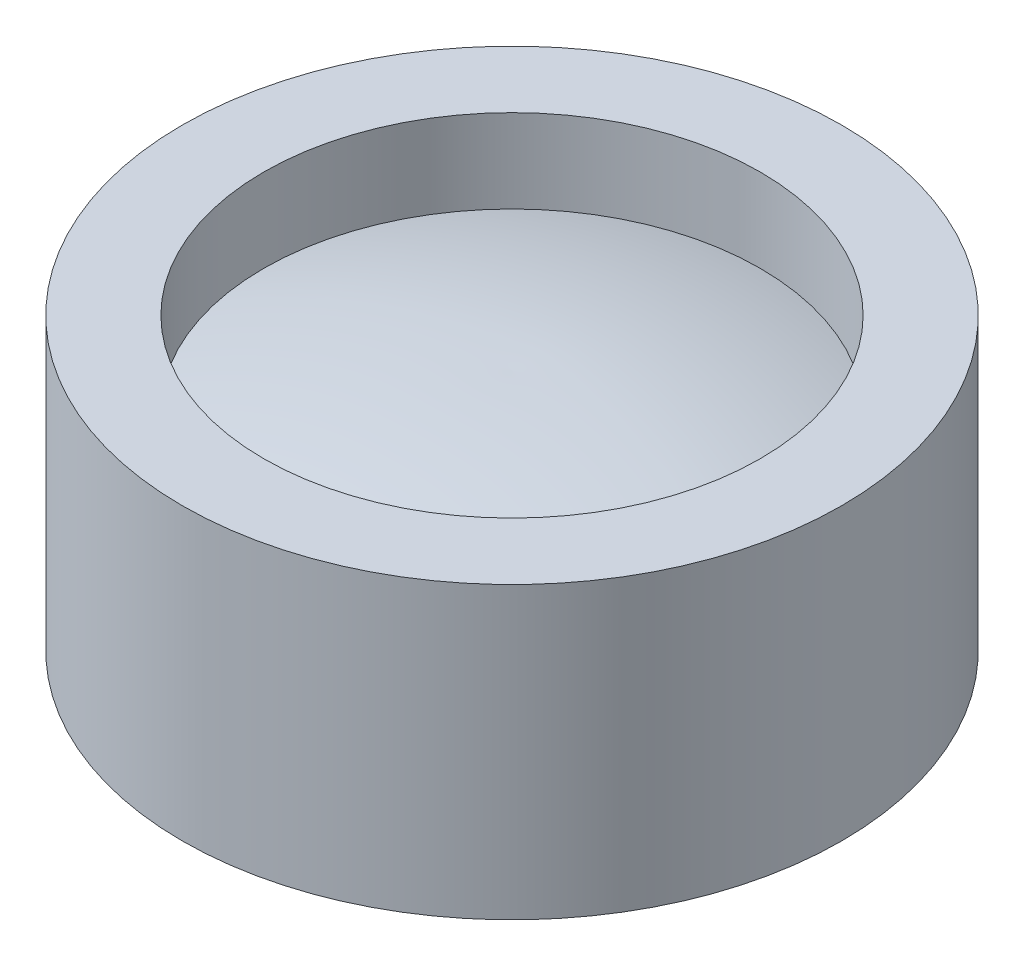
from build123d import *


with BuildPart() as part:
    # Sketch1 → Revolve1 (revolve)
    with BuildSketch(Plane.XY):
        with BuildLine():
            Line((0, 0), (1.88, 0))
            Line((1.88, 0), (1.88, -0.2))
            Line((1.88, -0.2), (2.43, -0.2))
            Line((2.43, -0.2), (2.43, 1.94))
            Line((2.43, 1.94), (1.83, 1.94))
            Line((1.83, 1.94), (1.83, 1.325012736))
            add(Edge.make_bspline(
                [(1.83, 1.325012736), (0.931309896, 1.606367381), (0, 1.59)],
                knots=[0, 0, 0, 1, 1, 1], degree=2))
            Line((0, 1.59), (0, 0))
        make_face()
    revolve(axis=Axis((0, 0, 0), (0, 1, 0)))


solid = part.part
